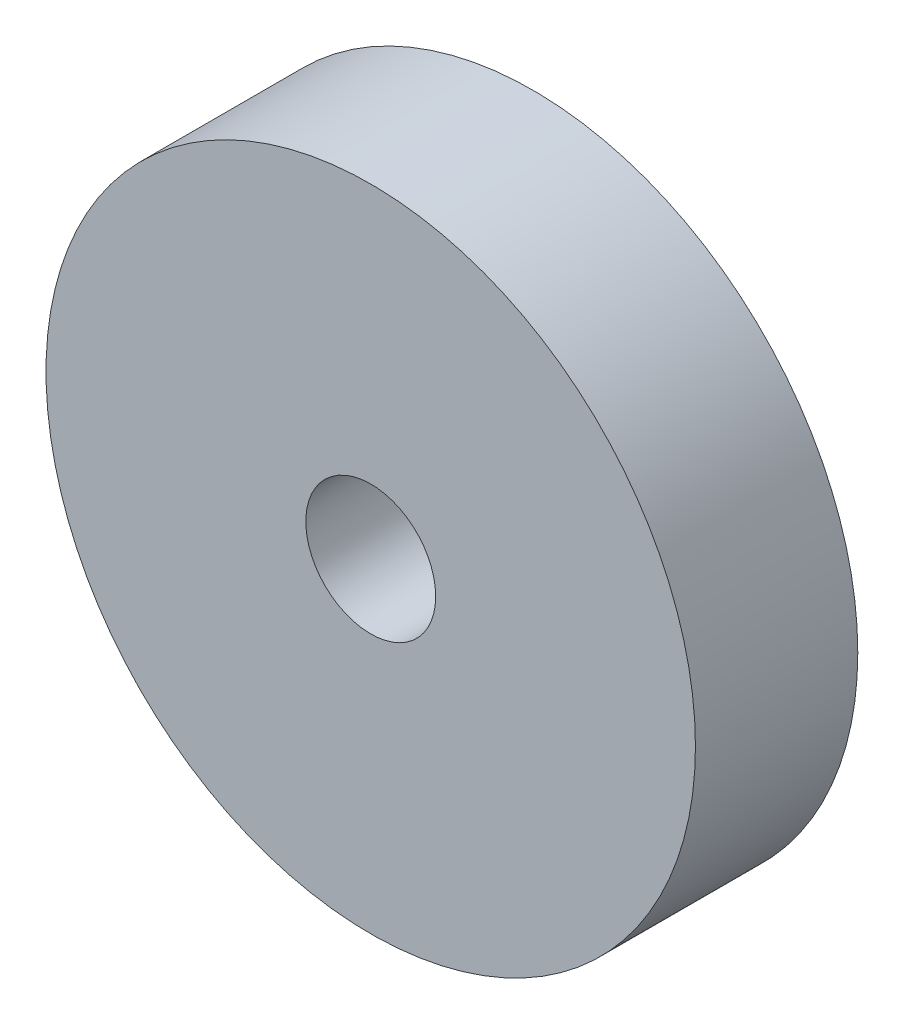
from build123d import *

# Parameters (mm, degrees)
CROQUIS1_R              = 0.5
CROQUIS1_R_2            = 0.1
SALIENTE_EXTRUIR1_DEPTH = 0.25


with BuildPart() as part:
    # Croquis1 → Saliente-Extruir1 (new body)
    with BuildSketch(Plane.XY):
        Circle(CROQUIS1_R)
        Circle(CROQUIS1_R_2, mode=Mode.SUBTRACT)
    extrude(amount=SALIENTE_EXTRUIR1_DEPTH)


solid = part.part
